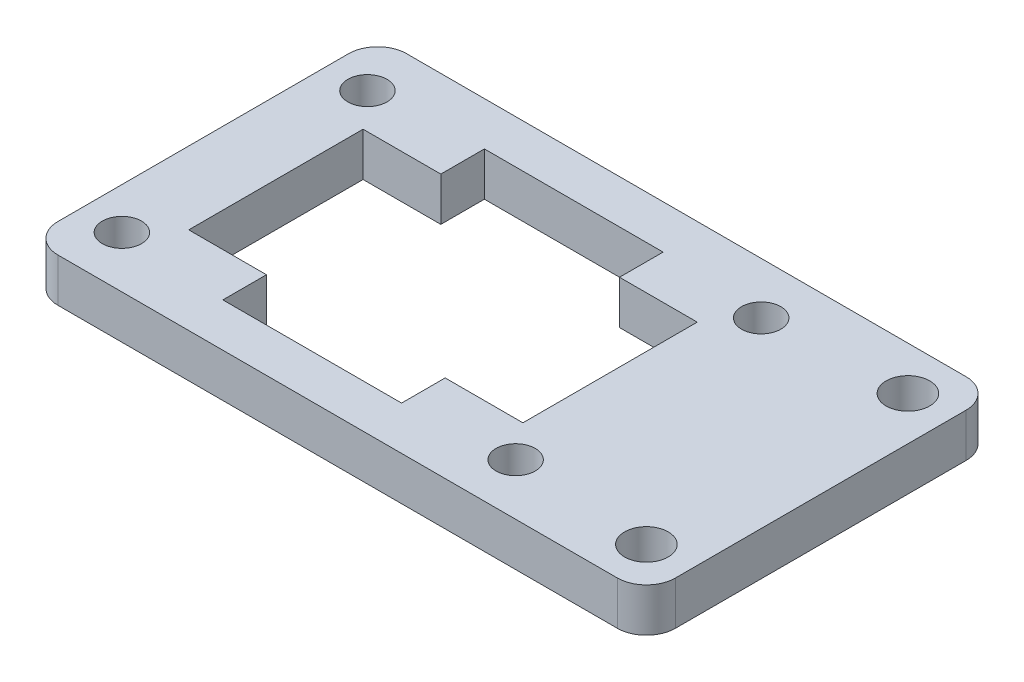
from build123d import *

# Parameters (mm, degrees)
SKETCH1_W           = 42.5
SKETCH1_H           = 24
SKETCH1_R           = 1.35
SKETCH1_R_2         = 1.5
BOSS_EXTRUDE1_DEPTH = 3
SKETCH2_W           = 0.15
SKETCH2_H           = 3
CUT_EXTRUDE1_DEPTH  = 4
FILLET1_R           = 2


with BuildPart() as part:
    # Sketch1 → Boss-Extrude1 (new body)
    with BuildSketch(Plane(origin=(0, 0, 0), x_dir=(1, 0, 0), z_dir=(0, 1, 0))):
        with Locations((21.25, 12)):
            Rectangle(SKETCH1_W, SKETCH1_H)
        with Locations((2.85, 3.55)):
            Circle(SKETCH1_R, mode=Mode.SUBTRACT)
        with Locations((29.95, 3.55)):
            Circle(SKETCH1_R, mode=Mode.SUBTRACT)
        with Locations((39.5, 3)):
            Circle(SKETCH1_R_2, mode=Mode.SUBTRACT)
        Polygon((5, 6), (5, 18), (10.5, 18), (10.5, 21), (22.5, 21), (22.5, 18), (28, 18), (28, 6), (22.5, 6), (22.5, 3), (10.5, 3), (10.5, 6), align=None, mode=Mode.SUBTRACT)
        with Locations((2.85, 20.45)):
            Circle(SKETCH1_R, mode=Mode.SUBTRACT)
        with Locations((29.95, 20.45)):
            Circle(SKETCH1_R, mode=Mode.SUBTRACT)
        with Locations((39.5, 21)):
            Circle(SKETCH1_R_2, mode=Mode.SUBTRACT)
    extrude(amount=BOSS_EXTRUDE1_DEPTH)

    # Sketch2 → Cut-Extrude1 (cut, through all)
    with BuildSketch(Plane(origin=(0, 3, 0), x_dir=(1, 0, 0), z_dir=(0, 1, 0))):
        with Locations((22.575, 4.5)):
            Rectangle(SKETCH2_W, SKETCH2_H)
        with Locations((10.425, 4.5)):
            Rectangle(SKETCH2_W, SKETCH2_H)
        with Locations((22.575, 19.5)):
            Rectangle(SKETCH2_W, SKETCH2_H)
        with Locations((10.425, 19.5)):
            Rectangle(SKETCH2_W, SKETCH2_H)
    extrude(amount=-CUT_EXTRUDE1_DEPTH, mode=Mode.SUBTRACT)

    # Fillet1
    fillet1_edges = [part.edges().sort_by_distance(p)[0] for p in [
        (0, 1.5, 0),
        (0, 1.5, -24),
        (42.5, 1.5, -24),
        (42.5, 1.5, 0),
    ]]
    fillet(fillet1_edges, radius=FILLET1_R)


solid = part.part
